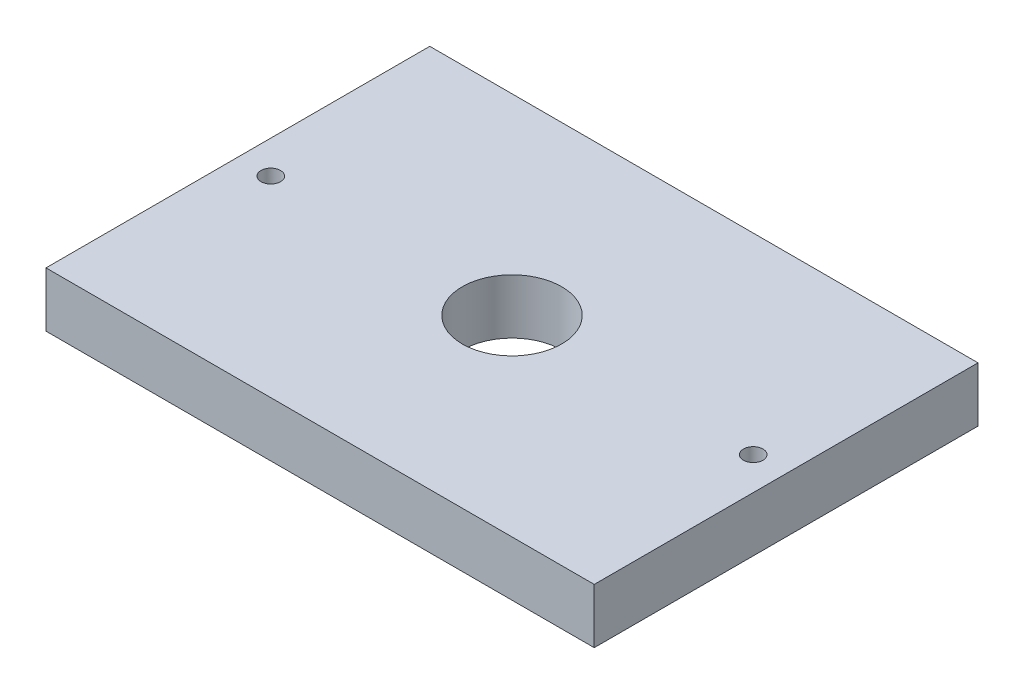
from build123d import *

# Parameters (mm, degrees)
SKETCH1_W                       = 63.5
SKETCH1_H                       = 44.45
BOSS_EXTRUDE1_DEPTH             = 6.35
LPATTERN1_COUNT                 = 2
LPATTERN1_PITCH                 = 55.88
TAP_DRILL_FOR_1_2_20_TAP1_D     = 11.50874
TAP_DRILL_FOR_1_2_20_TAP1_DEPTH = 6.35
TAP_DRILL_FOR_1_2_20_TAP1_TIP   = 3.45757432


with BuildPart() as part:
    # Sketch1 → Boss-Extrude1 (new body)
    with BuildSketch(Plane(origin=(0, 0, 0), x_dir=(1, 0, 0), z_dir=(0, 1, 0))):
        with Locations((4.75259427, -18.964156798)):
            Rectangle(SKETCH1_W, SKETCH1_H)
    extrude(amount=BOSS_EXTRUDE1_DEPTH)

    # Sketch16 → Tap Drill for #4-40 Tap1 (revolve, cut)
    with BuildSketch(Plane(origin=(-23.18740573, 0, 18.964156798), x_dir=(0, 0, -1), z_dir=(1, 0, 0))):
        Polygon((0, 0), (0, 13.379152758), (1.1303, 12.7), (1.1303, 0), align=None)
    tap_drill_for_4_40_tap1 = revolve(axis=Axis((-23.18740573, -6.35, 18.964156798), (0, 1, 0)), mode=Mode.SUBTRACT)

    # LPattern1: Tap Drill for #4-40 Tap1 ×2
    with Locations(*[(i * LPATTERN1_PITCH, 0, 0) for i in range(1, LPATTERN1_COUNT)]):
        add(tap_drill_for_4_40_tap1, mode=Mode.SUBTRACT)

    # Tap Drill for 1/2-20 Tap1
    with Locations(Plane(origin=(0, 6.35, 0), x_dir=(-1, 0, 0), z_dir=(0, 1, 0))):
        with Locations((-4.75259427, 18.964156798)):
            Hole(TAP_DRILL_FOR_1_2_20_TAP1_D / 2, depth=TAP_DRILL_FOR_1_2_20_TAP1_DEPTH)
            with Locations((0, 0, -(TAP_DRILL_FOR_1_2_20_TAP1_DEPTH + TAP_DRILL_FOR_1_2_20_TAP1_TIP / 2))):  # 118° drill point
                Cone(0, TAP_DRILL_FOR_1_2_20_TAP1_D / 2, TAP_DRILL_FOR_1_2_20_TAP1_TIP, mode=Mode.SUBTRACT)


solid = part.part
